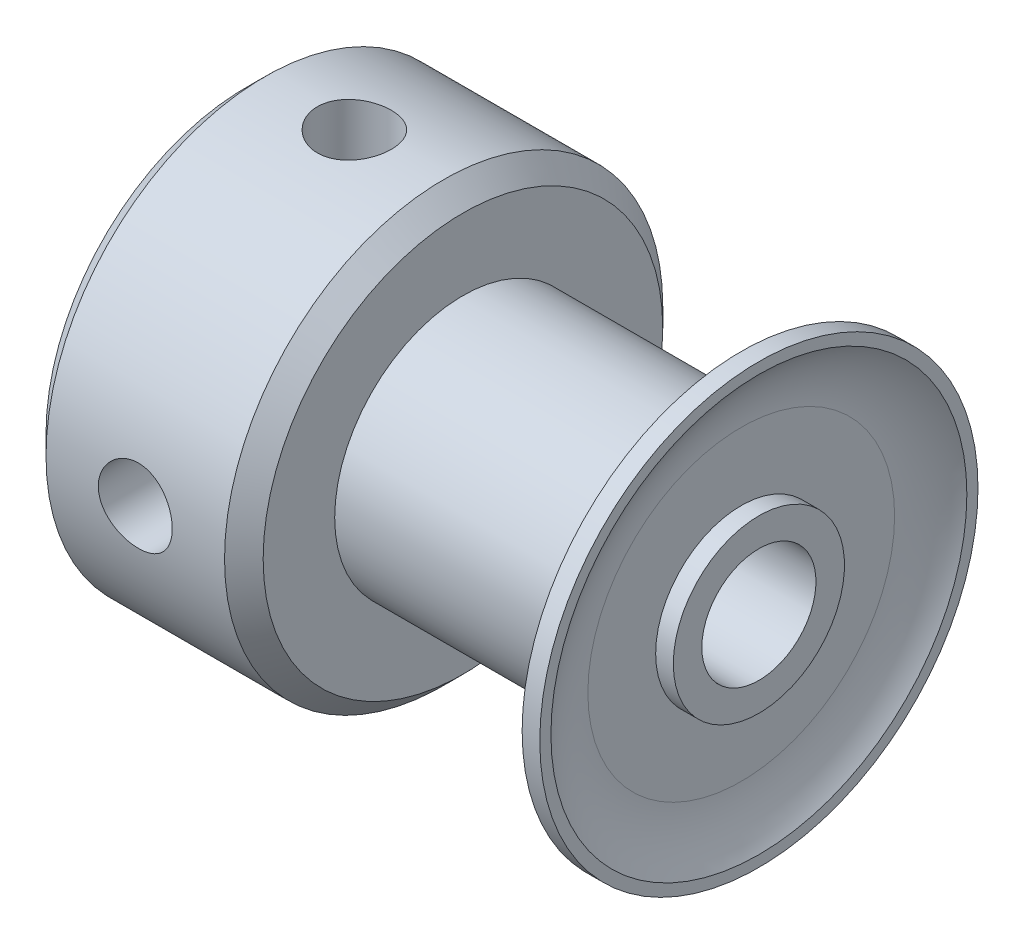
from build123d import *

# Parameters (mm, degrees)
SKETCH5_R         = 1.0287
SET_SCREWS_DEPTH  = 10
CIRPATTERN1_COUNT = 2
CIRPATTERN1_ANGLE = 90


with BuildPart() as part:
    # Sketch2 → Base Body (revolve)
    with BuildSketch(Plane.XY):
        Polygon((-7.1374, 1.5875), (7.1374, 1.5875), (7.1374, 2.38125), (6.06679, 2.38125), (6.06679, 3.5687), (-1.09601, 3.5687), (-1.09601, 2.38125), (-7.1374, 2.38125), align=None)
    revolve(axis=Axis((-7.1374, 0, 0), (1, 0, 0)))


with BuildPart() as body_2:
    # Sketch3 → Hub (revolve)
    with BuildSketch(Plane(origin=(0, 0, 0), x_dir=(1, 0, 0), z_dir=(0, 1, 0))):
        Polygon((-1.09601, 2.38125), (-7.1374, 2.38125), (-7.1374, 5.55879), (-6.60019, 6.096), (-1.63322, 6.096), (-1.09601, 5.55879), align=None)
    revolve(axis=Axis((0, 0, 0), (-1, 0, 0)))


with BuildPart() as body_3:
    # Sketch4 → Flange (revolve)
    with BuildSketch(Plane(origin=(0, 0, 0), x_dir=(1, 0, 0), z_dir=(0, 1, 0))):
        with BuildLine():
            Line((6.06679, 2.38125), (6.06679, 4.2672))
            ThreePointArc((6.06679, 4.2672), (6.215155829, 5.226423955), (6.646387226, 6.096))
            Line((6.646387226, 6.096), (7.1374, 6.096))
            Line((7.1374, 6.096), (7.1374, 5.786297853))
            ThreePointArc((7.1374, 5.786297853), (6.772189303, 5.065440539), (6.646387226, 4.2672))
            Line((6.646387226, 4.2672), (6.646387226, 2.38125))
            Line((6.646387226, 2.38125), (6.06679, 2.38125))
        make_face()
    revolve(axis=Axis((0, 0, 0), (1, 0, 0)))


with BuildPart() as set_screws_tool:
    # Sketch5 → Set Screws (new body)
    with BuildSketch(Plane(origin=(0, 0, 0), x_dir=(1, 0, 0), z_dir=(0, 1, 0))):
        with Locations((-4.116705, 0)):
            Circle(SKETCH5_R)
    set_screws = extrude(amount=SET_SCREWS_DEPTH)


with BuildPart() as part_1:
    add(part.part)

    # Set Screws: cut by set_screws_tool
    add(set_screws_tool.part, mode=Mode.SUBTRACT)


with BuildPart() as body_2_1:
    add(body_2.part)

    # Set Screws: cut by set_screws_tool
    add(set_screws_tool.part, mode=Mode.SUBTRACT)


with BuildPart() as cirpattern1_tool:
    # CirPattern1: Set Screws ×2 about axis
    cirpattern1_axis = Axis((-7.1374, 0, 0), (1, 0, 0))
    for i in range(1, CIRPATTERN1_COUNT):
        add(set_screws.rotate(cirpattern1_axis, i * CIRPATTERN1_ANGLE / (CIRPATTERN1_COUNT - 1)))


with BuildPart() as part_2:
    add(part_1.part)

    # CirPattern1: cut by cirpattern1_tool
    add(cirpattern1_tool.part, mode=Mode.SUBTRACT)


with BuildPart() as body_2_2:
    add(body_2_1.part)

    # CirPattern1: cut by cirpattern1_tool
    add(cirpattern1_tool.part, mode=Mode.SUBTRACT)


solid = Compound([body_3.part, part_2.part, body_2_2.part])
